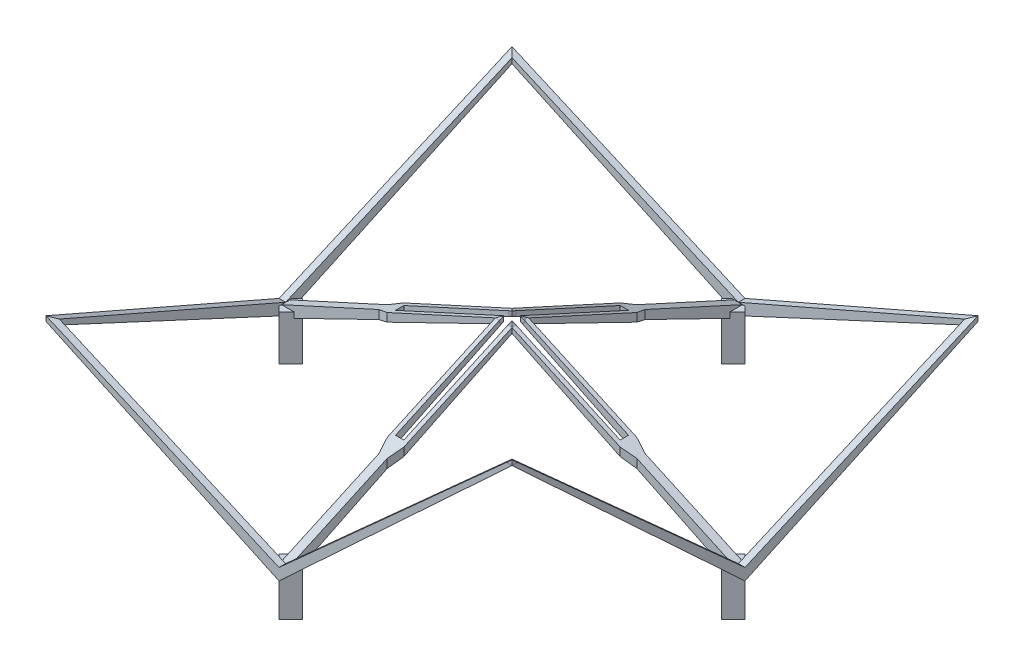
from build123d import *

# Parameters (mm, degrees)
V_CENTRAL_DEPTH           = 500
V_CENTRAL_2_DEPTH         = 500
SALIENTE_EXTRUIR2_DEPTH   = 1000
SALIENTE_EXTRUIR2_2_DEPTH = 1000
HUECO_W                   = 13500
HUECO_H                   = 500
HUECO_CENITAL_DEPTH       = 9837
MATRIZC12_COUNT           = 2
MATRIZC12_ANGLE           = 90
CORTAR_EXTRUIR3_DEPTH     = 150
CORTAR_EXTRUIR4_DEPTH     = 150
CORTAR_EXTRUIR5_DEPTH     = 150
CORTAR_EXTRUIR6_DEPTH     = 150
VIGA_BORDE_C_1_DEPTH      = 400
MATRIZC15_COUNT           = 2
MATRIZC15_ANGLE           = 90
CORTAR_EXTRUIR7_DEPTH     = 400
CROQUIS14_W               = 659.443586075
CROQUIS14_H               = 500.557822025
CORTAR_EXTRUIR8_DEPTH     = 400
VIGA_BORDE_A_3_DEPTH      = 400
MATRIZC16_COUNT           = 2
MATRIZC16_ANGLE           = 90
CORTAR_EXTRUIR9_DEPTH     = 400
CORTAR_EXTRUIR10_DEPTH    = 400
CORTAR_EXTRUIR11_DEPTH    = 400
CORTAR_EXTRUIR12_DEPTH    = 400
CORTAR_EXTRUIR13_DEPTH    = 400
CORTAR_EXTRUIR14_DEPTH    = 400
SALIENTE_EXTRUIR6_DEPTH   = 2700
SALIENTE_EXTRUIR6_2_DEPTH = 2700
SALIENTE_EXTRUIR6_3_DEPTH = 2700
SALIENTE_EXTRUIR6_4_DEPTH = 2700


with BuildPart() as part:
    # Croquis5 → V Central (new body)
    with BuildSketch(Plane.XY.offset(250)):
        Polygon((-13600.08949546, 2000), (-13000.08949546, 2000), (-13000.08949546, 2150), (-13100.08949546, 2150), (-13100.08949546, 2100), (-13394.703503223, 2100), (-7750, 4848.339086672), (-7750, 5373.056681339), (-13600.08949546, 2700), align=None)
    extrude(amount=-V_CENTRAL_DEPTH)


with BuildPart() as body_2:
    # Croquis5 → V Central 2 (new body)
    with BuildSketch(Plane.XY.offset(250)):
        Polygon((7750, 5373.056681339), (7750, 4848.339086672), (13394.703503223, 2100), (13099.711971619, 2100), (13099.711971619, 2150), (12999.711971619, 2150), (12999.711971619, 2000), (13600.089495461, 2000), (13600.089495461, 2700), align=None)
    extrude(amount=-V_CENTRAL_2_DEPTH)



with BuildPart() as body_3:
    # V Central Cenital → Saliente-Extruir2 (new body)
    with BuildSketch(Plane.XY.offset(500)):
        Polygon((7000, 5213.505178005), (7000, 5715.751013205), (250, 8800), (250, 8500), align=None)
    extrude(amount=-SALIENTE_EXTRUIR2_DEPTH)


with BuildPart() as body_4:
    # V Central Cenital → Saliente-Extruir2 2 (new body)
    with BuildSketch(Plane.XY.offset(500)):
        Polygon((-250, 8500), (-250, 8800), (-7000, 5715.751013205), (-7000, 5213.505178005), align=None)
    extrude(amount=-SALIENTE_EXTRUIR2_2_DEPTH)


    add(part.part)  # recubrir5 joins it to this body
    # loft from a face of the part (recubrir5)
    loft([body_4.faces().sort_by_distance((-7000, 5464.628095605, 0))[0], body_4.faces().sort_by_distance((-7750, 5110.697884006, 0))[0]])


with BuildPart() as body_2_1:
    add(body_2.part)

    add(body_3.part)  # recubrir6 joins it to this body
    # loft from a face of the part (recubrir6)
    loft([body_2_1.faces().sort_by_distance((7750, 5110.697884006, 0))[0], body_2_1.faces().sort_by_distance((7000, 5464.628095605, 0))[0]])


with BuildPart() as hueco_cenital_tool:
    # Hueco → Hueco cenital (new body)
    with BuildSketch(Plane(origin=(0, 0, 0), x_dir=(1, 0, 0), z_dir=(0, 1, 0))):
        Rectangle(HUECO_W, HUECO_H)
    extrude(amount=HUECO_CENITAL_DEPTH)


with BuildPart() as body_2_2:
    add(body_2_1.part)

    # Hueco cenital: cut by hueco_cenital_tool
    add(hueco_cenital_tool.part, mode=Mode.SUBTRACT)


with BuildPart() as body_4_1:
    add(body_4.part)

    # Hueco cenital: cut by hueco_cenital_tool
    add(hueco_cenital_tool.part, mode=Mode.SUBTRACT)


with BuildPart() as matrizc12_1:
    # MatrizC12: pattern copy
    add(body_2_2.part.rotate(Axis((0, 0, 0), (0, -1, 0)), 1 * MATRIZC12_ANGLE / (MATRIZC12_COUNT - 1)))


with BuildPart() as matrizc12_2:
    # MatrizC12: pattern copy
    add(body_4_1.part.rotate(Axis((0, 0, 0), (0, -1, 0)), 1 * MATRIZC12_ANGLE / (MATRIZC12_COUNT - 1)))


with BuildPart() as cortar_extruir3_tool:
    # Croquis8 → Cortar-Extruir3 (new body)
    with BuildSketch(Plane(origin=(3369.627388011, 7374.561835459, 0), x_dir=(0.9095491198215689, -0.4155964372222283, 0), z_dir=(0.4155964372222283, 0.9095491198215689, 0))):
        Polygon((-3429.8613676, -250), (-3155.097216856, -500), (-3155.097216856, -250), align=None)
        Polygon((-3429.8613676, 250), (-3154.961038643, 250), (-3154.961038643, 500), align=None)
    extrude(amount=CORTAR_EXTRUIR3_DEPTH)


with BuildPart() as matrizc12_1_1:
    add(matrizc12_1.part)

    # Cortar-Extruir3: cut by cortar_extruir3_tool
    add(cortar_extruir3_tool.part, mode=Mode.SUBTRACT)


with BuildPart() as matrizc12_2_1:
    add(matrizc12_2.part)

    # Cortar-Extruir3: cut by cortar_extruir3_tool
    add(cortar_extruir3_tool.part, mode=Mode.SUBTRACT)


with BuildPart() as cortar_extruir4_tool:
    # Croquis9 → Cortar-Extruir4 (new body)
    with BuildSketch(Plane(origin=(0, 7374.561835459, 3369.627388011), x_dir=(1, 0, 0), z_dir=(-1.4510472050511015e-15, 0.9095491198215689, 0.4155964372222283))):
        Polygon((250, 3429.8613676), (499.911491468, 3155.097216856), (250, 3155.097216856), align=None)
        Polygon((-250, 3429.8613676), (-500, 3154.918676232), (-250, 3154.918676232), align=None)
    extrude(amount=CORTAR_EXTRUIR4_DEPTH)


with BuildPart() as body_2_3:
    add(body_2_2.part)

    # Cortar-Extruir4: cut by cortar_extruir4_tool
    add(cortar_extruir4_tool.part, mode=Mode.SUBTRACT)


with BuildPart() as body_4_2:
    add(body_4_1.part)

    # Cortar-Extruir4: cut by cortar_extruir4_tool
    add(cortar_extruir4_tool.part, mode=Mode.SUBTRACT)


with BuildPart() as cortar_extruir5_tool:
    # Croquis10 → Cortar-Extruir5 (new body)
    with BuildSketch(Plane(origin=(-3369.627388011, 7374.561835459, 0), x_dir=(0.9095491198215687, 0.4155964372222282, 0), z_dir=(-0.4155964372222283, 0.9095491198215688, 0))):
        Polygon((3429.861367601, 250), (3155.017939079, 250), (3155.017939079, 500), align=None)
        Polygon((3155.098061094, -250), (3429.861367601, -250), (3155.098061094, -500), align=None)
    extrude(amount=CORTAR_EXTRUIR5_DEPTH)


with BuildPart() as matrizc12_1_2:
    add(matrizc12_1_1.part)

    # Cortar-Extruir5: cut by cortar_extruir5_tool
    add(cortar_extruir5_tool.part, mode=Mode.SUBTRACT)

    # Croquis12 → VIGA BORDE C-1 (add)
    with BuildSketch(Plane.XY.offset(14000)):
        Polygon((-14000, 8800), (0, 2700), (14000.089495461, 15300), (14000.089495461, 15000), (0, 2000), (-14000, 8500), align=None)
    viga_borde_c_1 = extrude(amount=-VIGA_BORDE_C_1_DEPTH)

    # MatrizC15: VIGA BORDE C-1 ×2 about axis
    matrizc15_axis = Axis((13800, 0, 13800), (0, -1, 0))
    for i in range(1, MATRIZC15_COUNT):
        add(viga_borde_c_1.rotate(matrizc15_axis, i * MATRIZC15_ANGLE / (MATRIZC15_COUNT - 1)))

    # Croquis13 → Cortar-Extruir7 (cut)
    with BuildSketch(Plane(origin=(0, 1491.721241974, -1342.540535542), x_dir=(1, 0, 0), z_dir=(2.283669573086975e-15, 0.7432962726122418, -0.6689623689870365))):
        Polygon((14046.458462562, -20641.204195829), (13600, -20641.338583716), (13600, -20103.074757832), (14046.458462562, -20103.074757832), align=None)
    extrude(amount=CORTAR_EXTRUIR7_DEPTH, mode=Mode.SUBTRACT)

    # Croquis14 → Cortar-Extruir8 (cut)
    with BuildSketch(Plane(origin=(-1342.540535542, 1491.721241974, 0), x_dir=(0.7432962726122418, 0.6689623689870365, 0), z_dir=(-0.6689623689870365, 0.7432962726122418, 0))):
        with Locations((20432.79655087, -13850.278911013)):
            Rectangle(CROQUIS14_W, CROQUIS14_H)
    extrude(amount=CORTAR_EXTRUIR8_DEPTH, mode=Mode.SUBTRACT)



with BuildPart() as matrizc12_2_2:
    add(matrizc12_2_1.part)

    # Cortar-Extruir5: cut by cortar_extruir5_tool
    add(cortar_extruir5_tool.part, mode=Mode.SUBTRACT)


with BuildPart() as cortar_extruir6_tool:
    # Croquis11 → Cortar-Extruir6 (new body)
    with BuildSketch(Plane(origin=(0, 7374.561835459, -3369.627388011), x_dir=(1, 0, 0), z_dir=(1.4510472050511017e-15, 0.9095491198215687, -0.4155964372222282))):
        Polygon((250, -3429.861367601), (250, -3154.620815718), (500, -3154.620815718), align=None)
        Polygon((-250, -3429.861367601), (-499.983598501, -3155.017939078), (-250, -3155.017939078), align=None)
    extrude(amount=CORTAR_EXTRUIR6_DEPTH)


with BuildPart() as body_2_4:
    add(body_2_3.part)

    # Cortar-Extruir6: cut by cortar_extruir6_tool
    add(cortar_extruir6_tool.part, mode=Mode.SUBTRACT)


with BuildPart() as body_4_3:
    add(body_4_2.part)

    # Cortar-Extruir6: cut by cortar_extruir6_tool
    add(cortar_extruir6_tool.part, mode=Mode.SUBTRACT)


with BuildPart() as matrizc12_1_3:
    add(matrizc12_1_2.part)

    add(matrizc12_2_2.part)  # VIGA BORDE A-3 merges MatrizC12_2
    # Croquis15 → VIGA BORDE A-3 (add)
    with BuildSketch(Plane.XY.offset(-14000)):
        Polygon((-14000, 8800), (0, 2700), (14000, 8800), (14000, 8499.958448801), (0, 2000), (-14000, 8500), align=None)
    viga_borde_a_3 = extrude(amount=VIGA_BORDE_A_3_DEPTH)

    # MatrizC16: VIGA BORDE A-3 ×2 about axis
    matrizc16_axis = Axis((-13800, 0, -13800), (0, -1, 0))
    for i in range(1, MATRIZC16_COUNT):
        add(viga_borde_a_3.rotate(matrizc16_axis, i * MATRIZC16_ANGLE / (MATRIZC16_COUNT - 1)))

    # Croquis16 → Cortar-Extruir9 (cut)
    with BuildSketch(Plane(origin=(-988.722610523, 2269.199433987, 0), x_dir=(0.916757456915312, 0.3994443205130973, 0), z_dir=(-0.3994443205130973, 0.916757456915312, 0))):
        Polygon((16349.71441733, 14000), (15913.393995846, 13600), (15913.393995846, 14000), align=None)
    extrude(amount=CORTAR_EXTRUIR9_DEPTH, mode=Mode.SUBTRACT)

    # Croquis17 → Cortar-Extruir10 (cut)
    with BuildSketch(Plane(origin=(0, 2269.199433987, 988.722610523), x_dir=(1, 0, 0), z_dir=(-1.4587875677430013e-15, 0.9167574569153109, 0.39944432051309986))):
        Polygon((14000, 15913.393995846), (14000, 16349.71441733), (13600, 15913.393995846), align=None)
    extrude(amount=CORTAR_EXTRUIR10_DEPTH, mode=Mode.SUBTRACT)

    # Croquis18 → Cortar-Extruir11 (cut)
    with BuildSketch(Plane(origin=(0, 2269.199433987, 988.722610523), x_dir=(1, 0, 0), z_dir=(-1.6017007930813528e-15, 0.916757456915311, 0.3994443205130998))):
        Polygon((-14000, 16349.714417329), (-14000, 15913.393995846), (-13600, 15913.393995845), align=None)
    extrude(amount=CORTAR_EXTRUIR11_DEPTH, mode=Mode.SUBTRACT)

    # Croquis19 → Cortar-Extruir12 (cut)
    with BuildSketch(Plane(origin=(988.722610523, 2269.199433987, 0), x_dir=(0.916757456915311, -0.3994443205130998, 0), z_dir=(0.3994443205130998, 0.916757456915311, 0))):
        Polygon((-15913.393995845, 14000), (-16349.714417329, 14000), (-15913.393995845, 13600), align=None)
    extrude(amount=CORTAR_EXTRUIR12_DEPTH, mode=Mode.SUBTRACT)

    # Croquis20 → Cortar-Extruir13 (cut)
    with BuildSketch(Plane(origin=(988.722610523, 2269.199433987, 0), x_dir=(0.916757456915311, -0.3994443205130998, 0), z_dir=(0.3994443205130998, 0.916757456915311, 0))):
        Polygon((-16349.71441733, -14000), (-15913.393995845, -13600), (-15913.393995845, -14000), align=None)
    extrude(amount=CORTAR_EXTRUIR13_DEPTH, mode=Mode.SUBTRACT)

    # Croquis21 → Cortar-Extruir14 (cut)
    with BuildSketch(Plane(origin=(0, 2269.199433986, -988.722610523), x_dir=(1, 0, 0), z_dir=(1.1876039888753645e-15, 0.916757456915312, -0.3994443205130973))):
        Polygon((-14000, -15830.076145405), (-14000, -16349.71441733), (-13600, -15913.393995845), (-13600, -15830.076145405), align=None)
    extrude(amount=CORTAR_EXTRUIR14_DEPTH, mode=Mode.SUBTRACT)


with BuildPart() as body_4_2_1:
    # Planta → Saliente-Extruir6 (new body)
    with BuildSketch(Plane(origin=(0, 0, 0), x_dir=(1, 0, 0), z_dir=(0, 1, 0))):
        Polygon((0, 12585.786437627), (707.106781187, 13292.893218813), (0, 14000), (-707.106781187, 13292.893218813), align=None)
    extrude(amount=SALIENTE_EXTRUIR6_DEPTH)


with BuildPart() as body_5:
    # Planta → Saliente-Extruir6 2 (new body)
    with BuildSketch(Plane(origin=(0, 0, 0), x_dir=(1, 0, 0), z_dir=(0, 1, 0))):
        Polygon((14000, 0), (13292.893218813, 707.106781187), (12585.786437627, 0), (13292.893218813, -707.106781187), align=None)
    extrude(amount=SALIENTE_EXTRUIR6_2_DEPTH)


with BuildPart() as body_6:
    # Planta → Saliente-Extruir6 3 (new body)
    with BuildSketch(Plane(origin=(0, 0, 0), x_dir=(1, 0, 0), z_dir=(0, 1, 0))):
        Polygon((-707.106781187, -13292.893218813), (0, -14000), (707.106781187, -13292.893218813), (0, -12585.786437627), align=None)
    extrude(amount=SALIENTE_EXTRUIR6_3_DEPTH)


with BuildPart() as body_7:
    # Planta → Saliente-Extruir6 4 (new body)
    with BuildSketch(Plane(origin=(0, 0, 0), x_dir=(1, 0, 0), z_dir=(0, 1, 0))):
        Polygon((-13292.893218813, 707.106781187), (-14000, 0), (-13292.893218813, -707.106781187), (-12585.786437627, 0), align=None)
    extrude(amount=SALIENTE_EXTRUIR6_4_DEPTH)


solid = Compound([body_2_4.part, body_4_3.part, matrizc12_1_3.part, body_4_2_1.part, body_5.part, body_6.part, body_7.part])
